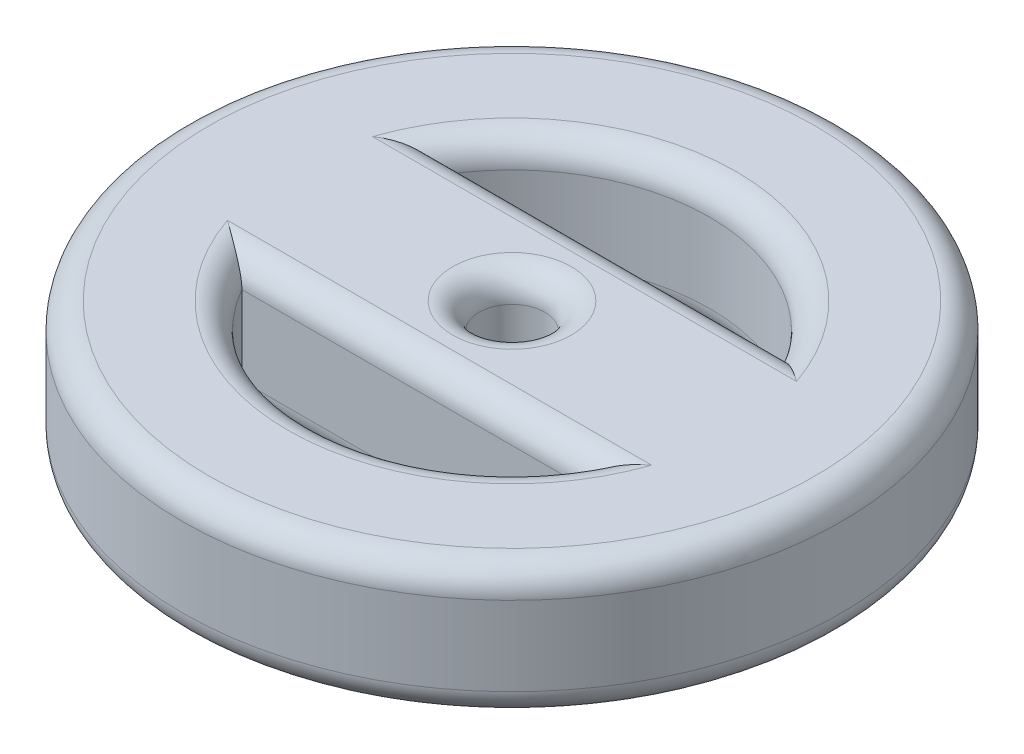
from build123d import *

# Parameters (mm, degrees)
ESQUISSE1_R      = 50
ESQUISSE1_R_2    = 5
EXTRUSION1_DEPTH = 20
CONG_1_R         = 4


with BuildPart() as part:
    # Esquisse1 → Extrusion1 (new body)
    with BuildSketch(Plane(origin=(0, 0, 0), x_dir=(1, 0, 0), z_dir=(0, 1, 0))):
        Circle(ESQUISSE1_R)
        Circle(ESQUISSE1_R_2, mode=Mode.SUBTRACT)
        with BuildLine():
            Line((-25.980762114, 15), (25.980762114, 15))
            ThreePointArc((25.980762114, 15), (0, 30), (-25.980762114, 15))
        make_face(mode=Mode.SUBTRACT)
        with BuildLine():
            Line((-25.980762114, -15), (25.980762114, -15))
            ThreePointArc((25.980762114, -15), (0, -30), (-25.980762114, -15))
        make_face(mode=Mode.SUBTRACT)
    extrude(amount=EXTRUSION1_DEPTH)

    # Congé1
    cong_1_edges = [part.edges().sort_by_distance(p)[0] for p in [
        (0, 0, 30),
        (0, 0, 15),
        (0, 20, 30),
        (0, 20, 15),
        (-50, 0, 0),
        (-5, 0, 0),
        (-5, 20, 0),
        (-50, 20, 0),
        (0, 0, -30),
        (0, 0, -15),
        (0, 20, -30),
        (0, 20, -15),
    ]]
    fillet(cong_1_edges, radius=CONG_1_R)


solid = part.part
